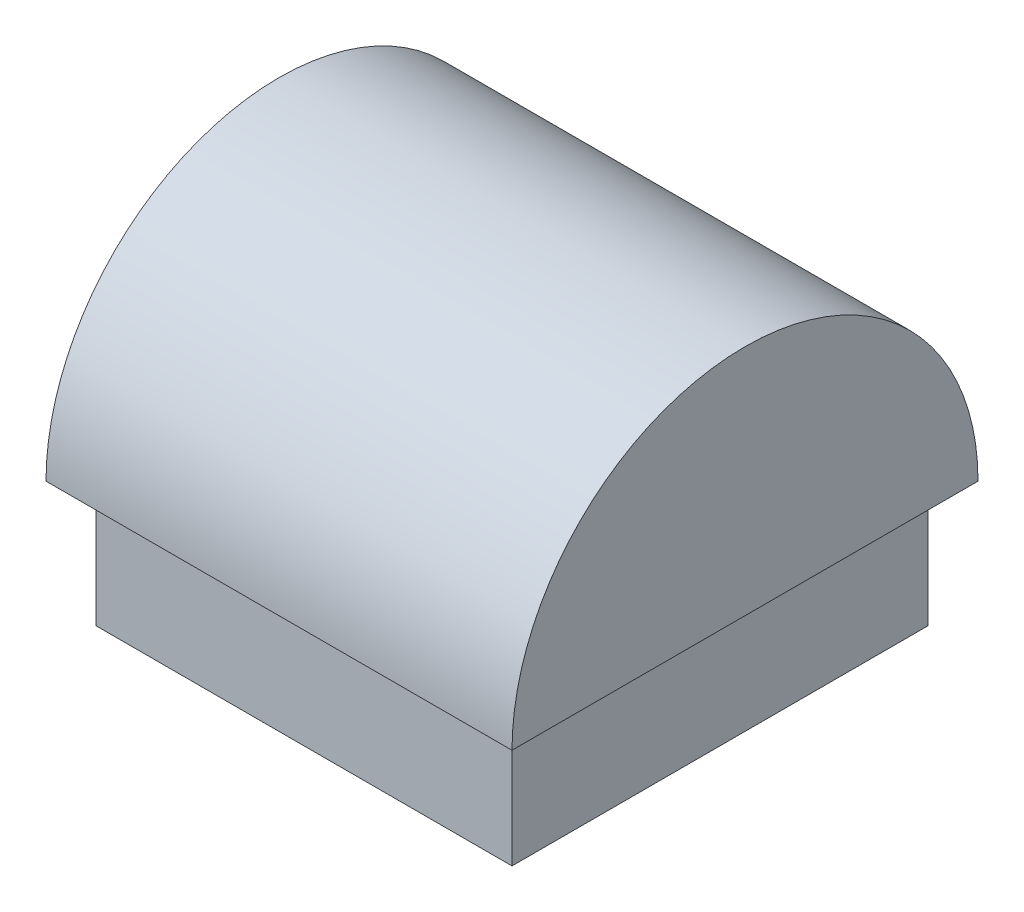
from build123d import *

# Parameters (mm, degrees)
SKETCH1_W           = 21.082
SKETCH1_H           = 21.082
BOSS_EXTRUDE1_DEPTH = 6.35
BOSS_EXTRUDE2_DEPTH = 11.811
SCALE1_SCALE        = 1.02


with BuildPart() as part:
    # Sketch1 → Boss-Extrude1 (new body)
    with BuildSketch(Plane(origin=(0, 0, 0), x_dir=(1, 0, 0), z_dir=(0, 1, 0))):
        Rectangle(SKETCH1_W, SKETCH1_H)
    extrude(amount=BOSS_EXTRUDE1_DEPTH)

    # Sketch3 → Boss-Extrude2 (add, symmetric)
    with BuildSketch(Plane(origin=(0, 0, 0), x_dir=(0, 0, -1), z_dir=(1, 0, 0))):
        with BuildLine():
            Line((-11.811, 6.35), (11.811, 6.35))
            ThreePointArc((11.811, 6.35), (0, 18.161), (-11.811, 6.35))
        make_face()
    extrude(amount=BOSS_EXTRUDE2_DEPTH, both=True)


with BuildPart() as part_1:
    # Scale1: scaled about (0, 8.473688703, 0)
    add(part.part.scale(SCALE1_SCALE).moved(Location((0, -0.169473774, 0))))


solid = part_1.part
